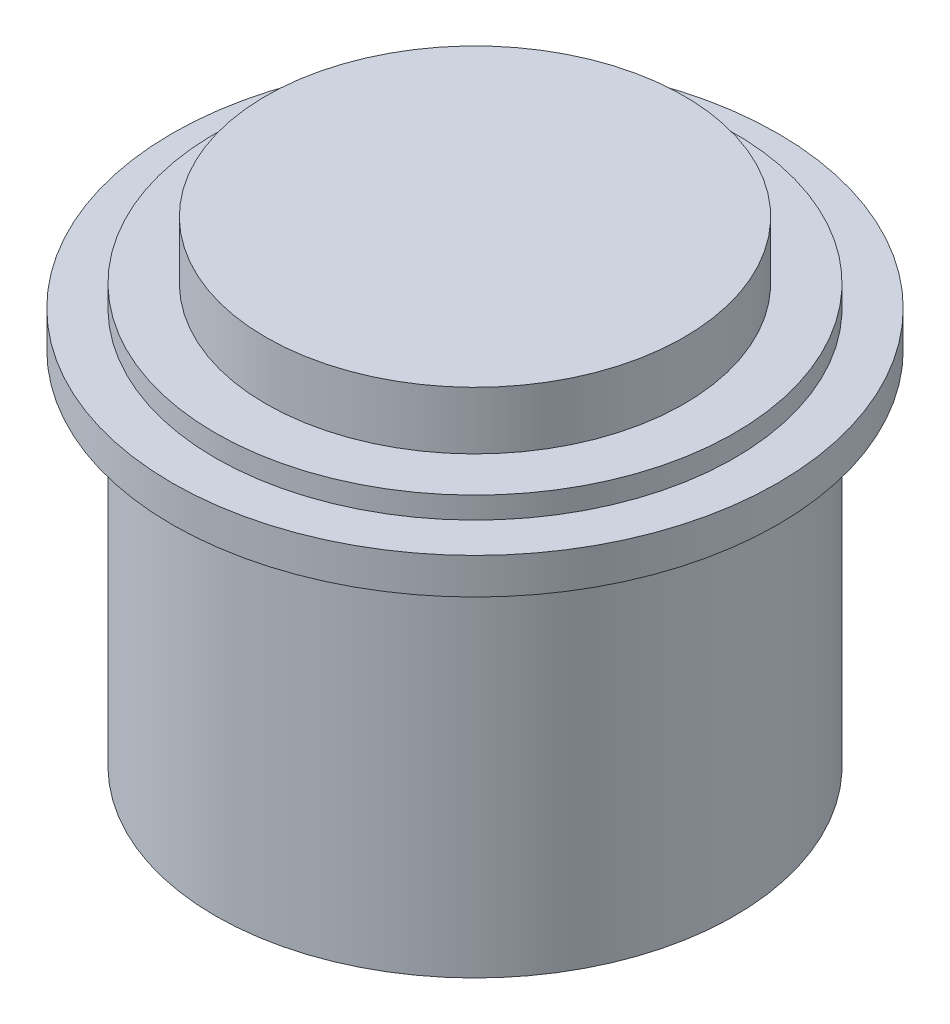
from build123d import *

# Parameters (mm, degrees)
SKETCH_2_R      = 29
EXTRUDE_1_DEPTH = 66
SKETCH_2_3_R    = 36
EXTRUDE_2_DEPTH = 58
EXTRUDE_START   = 50
SKETCH_2_4_R    = 42
SKETCH_2_4_R_2  = 36
EXTRUDE_3_DEPTH = 5


with BuildPart() as part:
    # 草图2 → 凸台-拉伸1 (new body)
    with BuildSketch(Plane(origin=(0, 0, 0), x_dir=(1, 0, 0), z_dir=(0, 1, 0))):
        with Locations((-35.483898972, -6.127114057)):
            Circle(SKETCH_2_R)
    extrude(amount=EXTRUDE_1_DEPTH)

    # 草图2<3> → 凸台-拉伸2 (add)
    with BuildSketch(Plane(origin=(0, 0, 0), x_dir=(1, 0, 0), z_dir=(0, 1, 0))):
        with Locations((-35.483898972, -6.127114057)):
            Circle(SKETCH_2_3_R)
    extrude(amount=EXTRUDE_2_DEPTH)

    # 草图2<4> → 凸台-拉伸3 (add)
    with BuildSketch(Plane(origin=(0, 0, 0), x_dir=(1, 0, 0), z_dir=(0, 1, 0)).offset(EXTRUDE_START)):
        with Locations((-35.483898972, -6.127114057)):
            Circle(SKETCH_2_4_R)
        with Locations((-35.483898972, -6.127114057)):
            Circle(SKETCH_2_4_R_2, mode=Mode.SUBTRACT)
    extrude(amount=EXTRUDE_3_DEPTH)


solid = part.part
